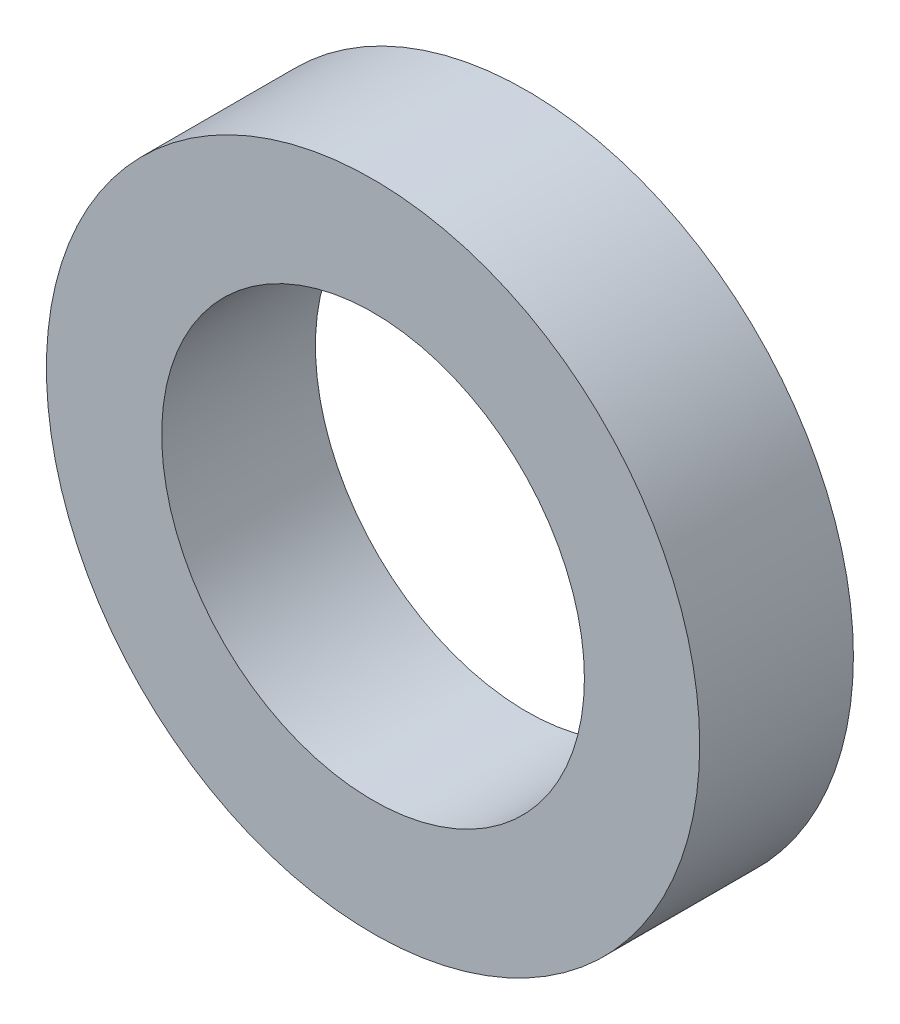
from build123d import *

# Parameters (mm, degrees)
SKETCH1_R           = 4.25
SKETCH1_R_2         = 2.75
BOSS_EXTRUDE1_DEPTH = 2


with BuildPart() as part:
    # Sketch1 → Boss-Extrude1 (new body)
    with BuildSketch(Plane.XY):
        Circle(SKETCH1_R)
        Circle(SKETCH1_R_2, mode=Mode.SUBTRACT)
    extrude(amount=BOSS_EXTRUDE1_DEPTH)


solid = part.part
